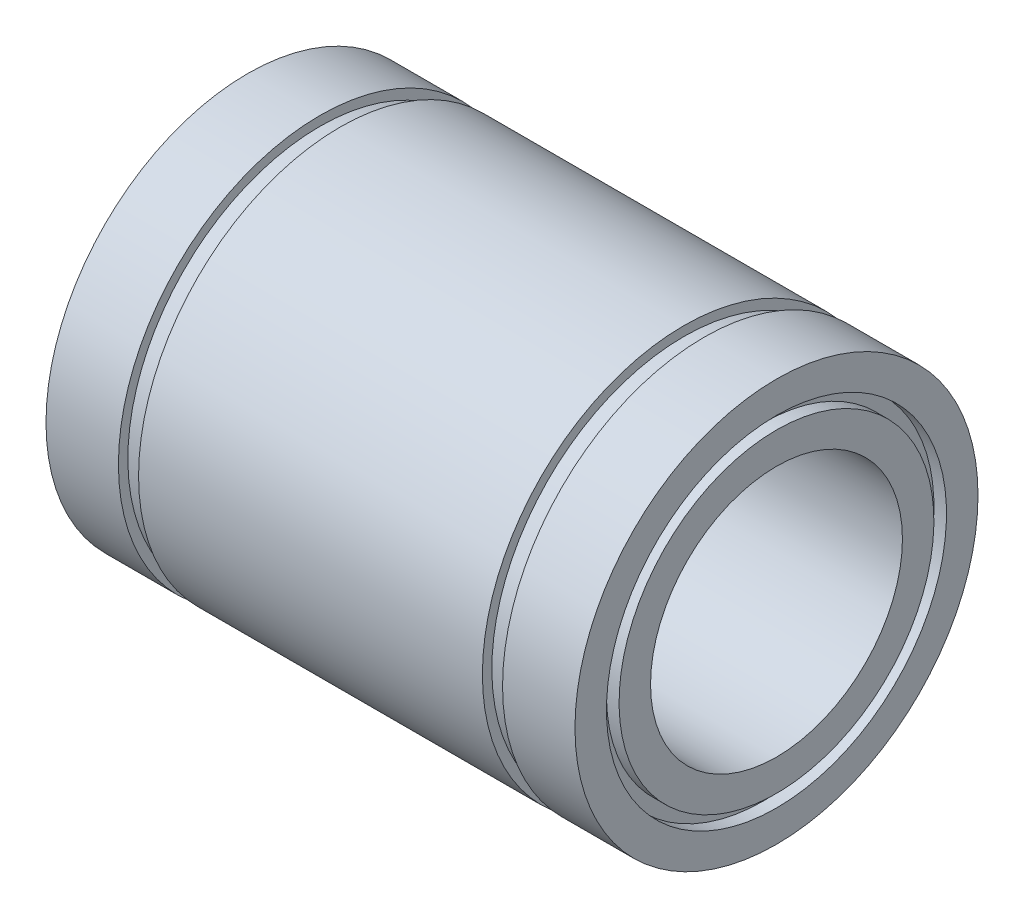
from build123d import *


with BuildPart() as part:
    # Esboço1 → Revolução1 (revolve)
    with BuildSketch(Plane.XY):
        Polygon((-21, 16), (-15.25, 16), (-15.25, 15.25), (-13.65, 15.25), (-13.65, 16), (13.65, 16), (13.65, 15.25), (15.25, 15.25), (15.25, 16), (21, 16), (21, 13.5), (20, 13.5), (20, 12.5), (21, 12.5), (21, 10), (-21, 10), (-21, 12.5), (-20, 12.5), (-20, 13.5), (-21, 13.5), align=None)
    revolve(axis=Axis((0, 0, 0), (-1, 0, 0)))


solid = part.part
